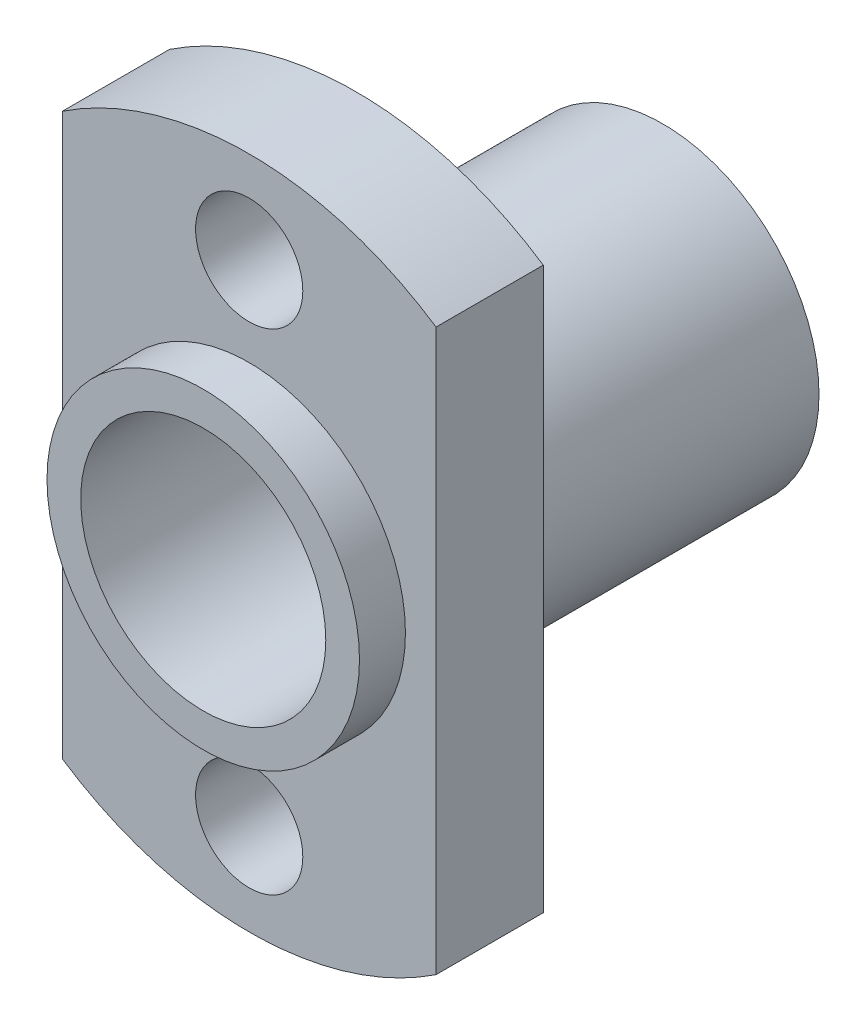
from build123d import *

# Parameters (mm, degrees)
SKETCH1_R                = 5.1
SKETCH1_R_2              = 1.75
BOSS_EXTRUDE1_DEPTH      = 3.5
SKETCH2_R                = 5.1
SKETCH2_R_2              = 4
BOSS_EXTRUDE2_DEPTH      = 1.5
BOSS_EXTRUDE2_DEPTH_BACK = 13.5


with BuildPart() as part:
    # Sketch1 → Boss-Extrude1 (new body)
    with BuildSketch(Plane.XY):
        with BuildLine():
            Line((-6.1, -9.153687781), (-6.1, 9.153687781))
            ThreePointArc((-6.1, 9.153687781), (0, 11), (6.1, 9.153687781))
            Line((6.1, 9.153687781), (6.1, -9.153687781))
            ThreePointArc((6.1, -9.153687781), (0, -11), (-6.1, -9.153687781))
        make_face()
        Circle(SKETCH1_R, mode=Mode.SUBTRACT)
        with Locations((0, 8)):
            Circle(SKETCH1_R_2, mode=Mode.SUBTRACT)
        with Locations((0, -8)):
            Circle(SKETCH1_R_2, mode=Mode.SUBTRACT)
    extrude(amount=-BOSS_EXTRUDE1_DEPTH)

    # Sketch2 → Boss-Extrude2 (add, two sides)
    with BuildSketch(Plane.XY) as boss_extrude2_sk:
        Circle(SKETCH2_R)
        Circle(SKETCH2_R_2, mode=Mode.SUBTRACT)
    extrude(amount=BOSS_EXTRUDE2_DEPTH)
    extrude(boss_extrude2_sk.sketch, amount=-BOSS_EXTRUDE2_DEPTH_BACK)


solid = part.part
